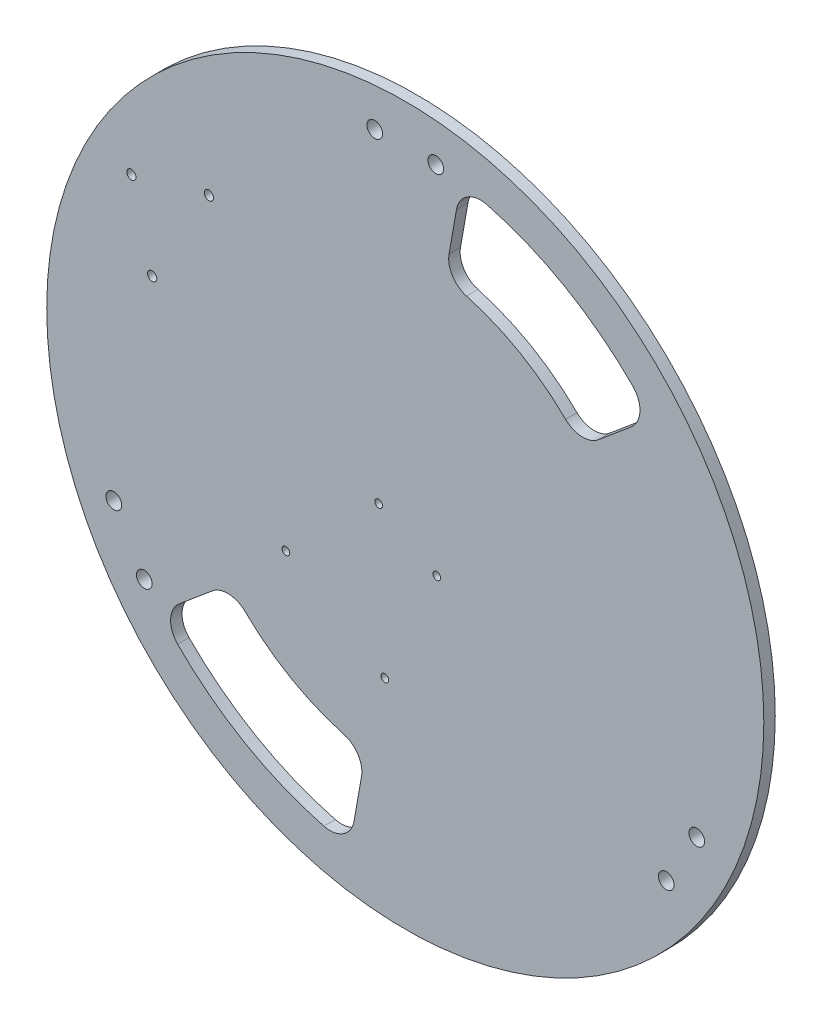
from build123d import *

# Parameters (mm, degrees)
BOSS_EXTRUDE1_DEPTH          = 4.762
SKETCH5_R                    = 1.926649595
MOTOR_MOUNTING_HOLES_DEPTH   = 5.762
SKETCH7_R                    = 1.5875
ARDUINO_MOUNTING_HOLES_DEPTH = 5.762
SKETCH9_R                    = 3.2639
F_1_4_20_FEET_HOLES_DEPTH    = 5.762
HANDLES_DEPTH                = 5.762


with BuildPart() as part:
    # Sketch1 → Boss-Extrude1 (new body)
    with BuildSketch(Plane.XY):
        with BuildLine():
            ThreePointArc((-80.354757502, -125.742648182), (-74.6125, -129.23264088), (-68.718948913, -132.460585403))
            ThreePointArc((-68.718948913, -132.460585403), (41.077351206, -143.459931141), (128.412526716, -76.015285354))
            ThreePointArc((128.412526716, -76.015285354), (129.23264088, -74.6125), (130.03743155, -73.200867623))
            ThreePointArc((130.03743155, -73.200867623), (-36.155935906, 144.778620396), (-80.354757502, -125.742648182))
        make_face()
    extrude(amount=BOSS_EXTRUDE1_DEPTH)

    # Sketch5 → motor_mounting_holes (cut, through all)
    with BuildSketch(Plane.XY.offset(4.762)):
        with Locations((-81.719743632, 74.457252102)):
            Circle(SKETCH5_R)
        with Locations((-113.98799572, 65.811000014)):
            Circle(SKETCH5_R)
        with Locations((-105.341743632, 33.542747925)):
            Circle(SKETCH5_R)
    extrude(amount=-MOTOR_MOUNTING_HOLES_DEPTH, mode=Mode.SUBTRACT)

    # Sketch7 → arduino mounting holes (cut, through all)
    with BuildSketch(Plane(origin=(0, 0, 0), x_dir=(-1, 0, 0), z_dir=(0, 0, -1))):
        with Locations((-13.114276913, -15.277418882)):
            Circle(SKETCH7_R)
        with Locations((8.521314036, -62.911361657)):
            Circle(SKETCH7_R)
        with Locations((11.082472869, -1.307418882)):
            Circle(SKETCH7_R)
        with Locations((49.680700023, -37.681509395)):
            Circle(SKETCH7_R)
    extrude(amount=-ARDUINO_MOUNTING_HOLES_DEPTH, mode=Mode.SUBTRACT)

    # Sketch9 → 1/4-20 feet holes (cut, through all)
    with BuildSketch(Plane.XY.offset(4.762)):
        with Locations((121.309555388, -55.373407621)):
            Circle(SKETCH9_R)
        with Locations((108.609555388, -77.370452877)):
            Circle(SKETCH9_R)
        with Locations((-108.609555388, -77.370452877)):
            Circle(SKETCH9_R)
        with Locations((-121.309555388, -55.373407621)):
            Circle(SKETCH9_R)
        with Locations((-12.7, 132.743860498)):
            Circle(SKETCH9_R)
        with Locations((12.7, 132.743860498)):
            Circle(SKETCH9_R)
    extrude(amount=-F_1_4_20_FEET_HOLES_DEPTH, mode=Mode.SUBTRACT)

    # Sketch8 → handles (cut, through all)
    with BuildSketch(Plane.XY.offset(4.762)):
        with BuildLine():
            Line((21.318841652, 120.905159074), (18.219031169, 103.325260238))
            ThreePointArc((18.219031169, 103.325260238), (19.630613539, 96.141801354), (25.504227054, 91.771983211))
            ThreePointArc((25.504227054, 91.771983211), (47.625, 82.48891971), (66.724755289, 67.973300138))
            ThreePointArc((66.724755289, 67.973300138), (73.445935569, 65.071510694), (80.372784634, 67.440773943))
            Line((80.372784634, 67.440773943), (94.047518381, 78.915237986))
            ThreePointArc((94.047518381, 78.915237986), (97.666057076, 86.231232388), (94.734676371, 93.848620624))
            ThreePointArc((94.734676371, 93.848620624), (66.675, 115.484487595), (33.907951385, 128.966946668))
            ThreePointArc((33.907951385, 128.966946668), (25.845409309, 127.696902709), (21.318841652, 120.905159074))
        make_face()
        with BuildLine():
            Line((-94.047518381, -78.915237986), (-80.372784634, -67.440773943))
            ThreePointArc((-80.372784634, -67.440773943), (-73.445935569, -65.071510694), (-66.724755289, -67.973300138))
            ThreePointArc((-66.724755289, -67.973300138), (-47.625, -82.48891971), (-25.504227054, -91.771983211))
            ThreePointArc((-25.504227054, -91.771983211), (-19.630613539, -96.141801354), (-18.219031169, -103.325260238))
            Line((-18.219031169, -103.325260238), (-21.318841652, -120.905159074))
            ThreePointArc((-21.318841652, -120.905159074), (-25.845409309, -127.696902709), (-33.907951385, -128.966946668))
            ThreePointArc((-33.907951385, -128.966946668), (-66.675, -115.484487595), (-94.734676371, -93.848620624))
            ThreePointArc((-94.734676371, -93.848620624), (-97.666057076, -86.231232388), (-94.047518381, -78.915237986))
        make_face()
    extrude(amount=-HANDLES_DEPTH, mode=Mode.SUBTRACT)


solid = part.part
